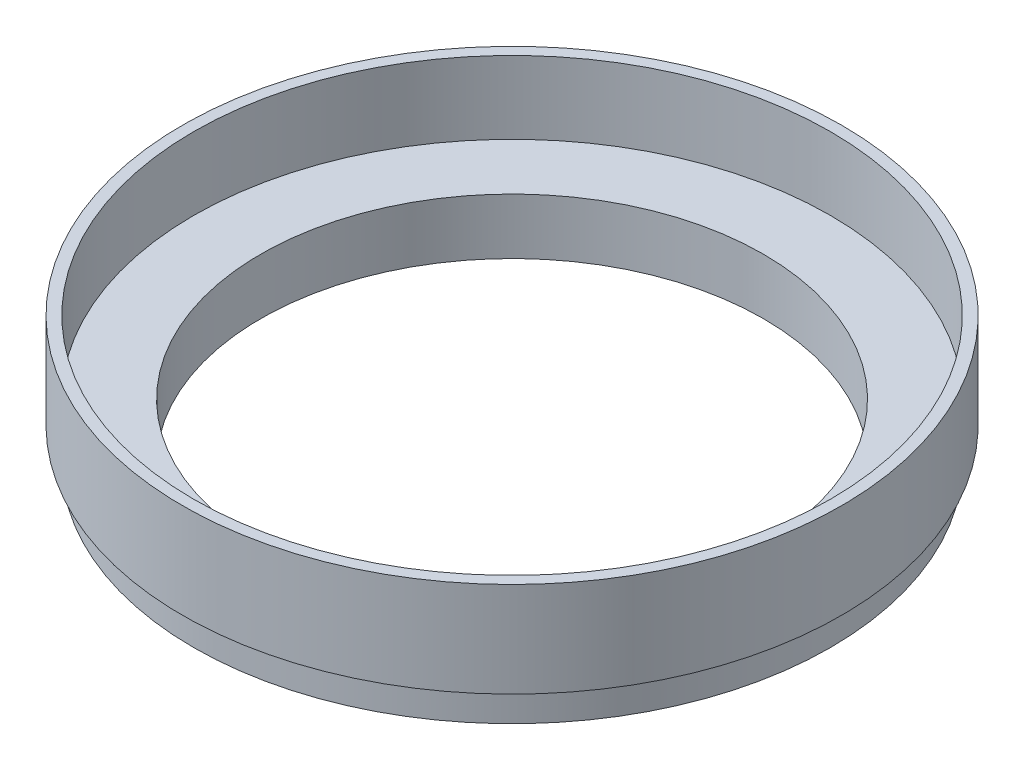
from build123d import *


with BuildPart() as part:
    # Schizzo1 → Rivoluzione1 (revolve)
    with BuildSketch(Plane.XY):
        Polygon((28.5, 0), (28.5, 3), (29.5, 3), (29.5, 11.5), (28.5, 11.5), (28.5, 5), (22.5, 5), (22.5, 0), (24.5, 0), (24.5, 2), (26.5, 2), (26.5, 0), align=None)
    revolve(axis=Axis((0, 0, 0), (0, 1, 0)))


solid = part.part
